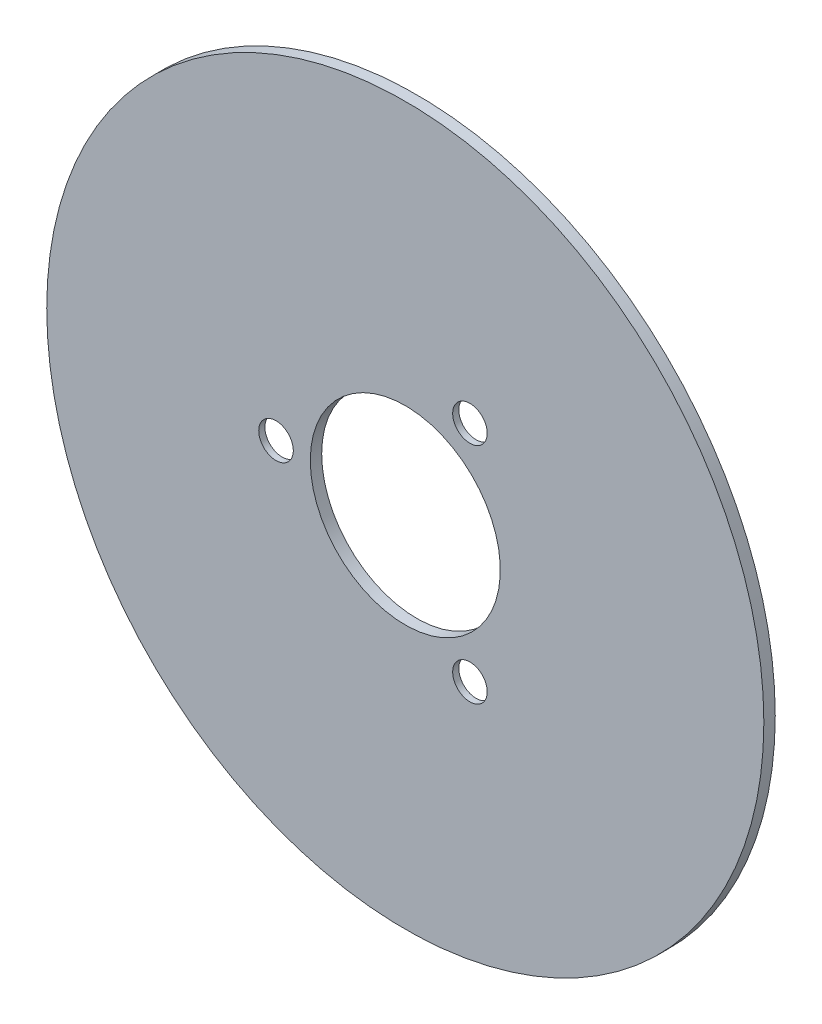
from build123d import *

# Parameters (mm, degrees)
SKETCH1_R           = 110
BOSS_EXTRUDE1_DEPTH = 3.5
SKETCH2_R           = 80
BOSS_EXTRUDE2_DEPTH = 0.001
SKETCH3_R           = 29.15
CUT_EXTRUDE1_DEPTH  = 4.5
SKETCH6_R           = 8.55
SKETCH6_R_2         = 5.3
CUT_EXTRUDE3_DEPTH  = 1.62
SKETCH7_R           = 5.3
CUT_EXTRUDE4_DEPTH  = 4.5
SKETCH8_R           = 80
CUT_EXTRUDE5_DEPTH  = 0.001


with BuildPart() as part:
    # Sketch1 → Boss-Extrude1 (new body)
    with BuildSketch(Plane.XY):
        Circle(SKETCH1_R)
    extrude(amount=BOSS_EXTRUDE1_DEPTH)

    # Sketch2 → Boss-Extrude2 (add)
    with BuildSketch(Plane(origin=(0, 0, 0), x_dir=(-1, 0, 0), z_dir=(0, 0, -1))):
        Circle(SKETCH2_R)
    extrude(amount=-BOSS_EXTRUDE2_DEPTH)

    # Sketch3 → Cut-Extrude1 (cut, through all)
    with BuildSketch(Plane(origin=(0, 0, 0), x_dir=(-1, 0, 0), z_dir=(0, 0, -1))):
        Circle(SKETCH3_R)
    extrude(amount=-CUT_EXTRUDE1_DEPTH, mode=Mode.SUBTRACT)

    # Sketch6 → Cut-Extrude3 (cut)
    with BuildSketch(Plane(origin=(0, 0, 0), x_dir=(-1, 0, 0), z_dir=(0, 0, -1))):
        with Locations((39.6625, 0)):
            Circle(SKETCH6_R)
        with Locations((39.6625, 0)):
            Circle(SKETCH6_R_2, mode=Mode.SUBTRACT)
        with Locations((-19.83125, -34.348732578)):
            Circle(SKETCH6_R)
        with Locations((-19.83125, -34.348732578)):
            Circle(SKETCH6_R_2, mode=Mode.SUBTRACT)
        with Locations((-19.83125, 34.348732578)):
            Circle(SKETCH6_R)
        with Locations((-19.83125, 34.348732578)):
            Circle(SKETCH6_R_2, mode=Mode.SUBTRACT)
    extrude(amount=-CUT_EXTRUDE3_DEPTH, mode=Mode.SUBTRACT)

    # Sketch7 → Cut-Extrude4 (cut, through all)
    with BuildSketch(Plane(origin=(0, 0, 0), x_dir=(-1, 0, 0), z_dir=(0, 0, -1))):
        with Locations((-19.83125, -34.348732578)):
            Circle(SKETCH7_R)
        with Locations((39.6625, 0)):
            Circle(SKETCH7_R)
        with Locations((-19.83125, 34.348732578)):
            Circle(SKETCH7_R)
    extrude(amount=-CUT_EXTRUDE4_DEPTH, mode=Mode.SUBTRACT)

    # Sketch8 → Cut-Extrude5 (cut)
    with BuildSketch(Plane(origin=(0, 0, 0), x_dir=(-1, 0, 0), z_dir=(0, 0, -1))):
        Circle(SKETCH8_R)
    extrude(amount=-CUT_EXTRUDE5_DEPTH, mode=Mode.SUBTRACT)


solid = part.part
